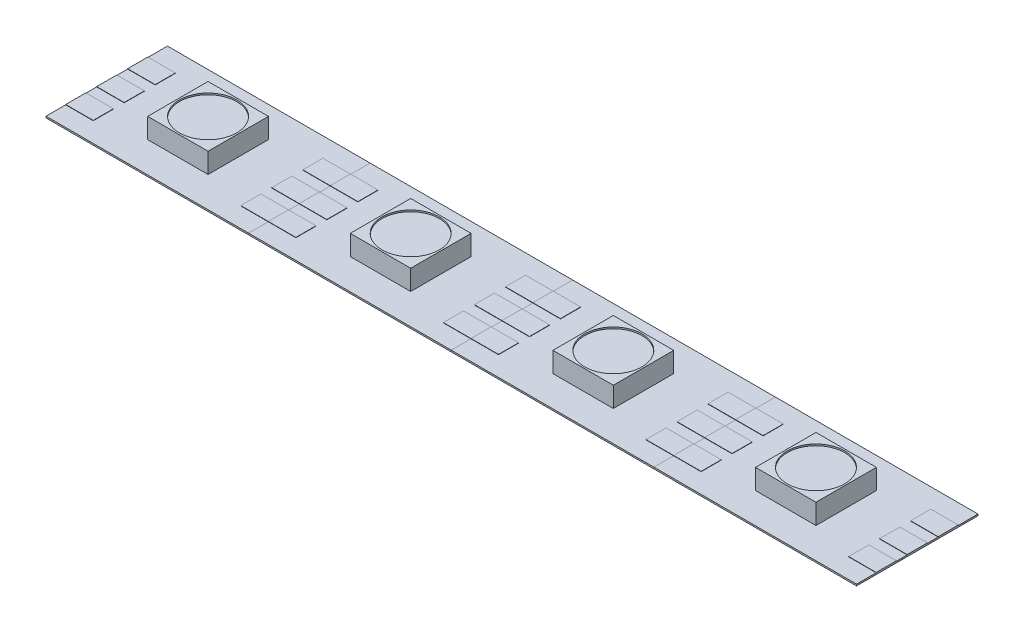
from build123d import *

# Parameters (mm, degrees)
SKETCH1_W           = 16.6116
SKETCH1_H           = 9.9568
BOSS_EXTRUDE1_DEPTH = 0.127
SKETCH3_W           = 4.953
SKETCH3_H           = 4.953
BOSS_EXTRUDE3_DEPTH = 1.651
SKETCH4_W           = 2.258810151
SKETCH4_H           = 1.651
BOSS_EXTRUDE4_DEPTH = 0.0254
SKETCH5_R           = 2.348345572
CUT_EXTRUDE1_DEPTH  = 0.127
LPATTERN1_COUNT     = 4
LPATTERN1_PITCH     = 16.6116


with BuildPart() as part:
    # Sketch1 → Boss-Extrude1 (new body)
    with BuildSketch(Plane(origin=(0, 0, 0), x_dir=(1, 0, 0), z_dir=(0, 1, 0))):
        Rectangle(SKETCH1_W, SKETCH1_H)
    extrude(amount=BOSS_EXTRUDE1_DEPTH)

    # Sketch3 → Boss-Extrude3 (add)
    with BuildSketch(Plane(origin=(0, 0.127, 0), x_dir=(1, 0, 0), z_dir=(0, 1, 0))):
        Rectangle(SKETCH3_W, SKETCH3_H)
    extrude(amount=BOSS_EXTRUDE3_DEPTH)

    # Sketch4 → Boss-Extrude4 (add)
    with BuildSketch(Plane(origin=(0, 0.127, 0), x_dir=(1, 0, 0), z_dir=(0, 1, 0))):
        with Locations((-7.176394925, 0)):
            Rectangle(SKETCH4_W, SKETCH4_H)
        with Locations((-7.176394925, 2.54)):
            Rectangle(SKETCH4_W, SKETCH4_H)
        with Locations((-7.176394925, -2.54)):
            Rectangle(SKETCH4_W, SKETCH4_H)
        with Locations((7.176394925, -2.54)):
            Rectangle(SKETCH4_W, SKETCH4_H)
        with Locations((7.176394925, 0)):
            Rectangle(SKETCH4_W, SKETCH4_H)
        with Locations((7.176394925, 2.54)):
            Rectangle(SKETCH4_W, SKETCH4_H)
    extrude(amount=BOSS_EXTRUDE4_DEPTH)

    # Sketch5 → Cut-Extrude1 (cut)
    with BuildSketch(Plane(origin=(0, 1.778, 0), x_dir=(1, 0, 0), z_dir=(0, 1, 0))):
        Circle(SKETCH5_R)
    extrude(amount=-CUT_EXTRUDE1_DEPTH, mode=Mode.SUBTRACT)


with BuildPart() as lpattern1_1:
    # LPattern1: pattern copy
    add(part.part.moved(Location(Vector(1, 0, 0) * (1 * LPATTERN1_PITCH))))


with BuildPart() as lpattern1_2:
    # LPattern1: pattern copy
    add(part.part.moved(Location(Vector(1, 0, 0) * (2 * LPATTERN1_PITCH))))


with BuildPart() as lpattern1_3:
    # LPattern1: pattern copy
    add(part.part.moved(Location(Vector(1, 0, 0) * (3 * LPATTERN1_PITCH))))


solid = Compound([part.part, lpattern1_1.part, lpattern1_2.part, lpattern1_3.part])
